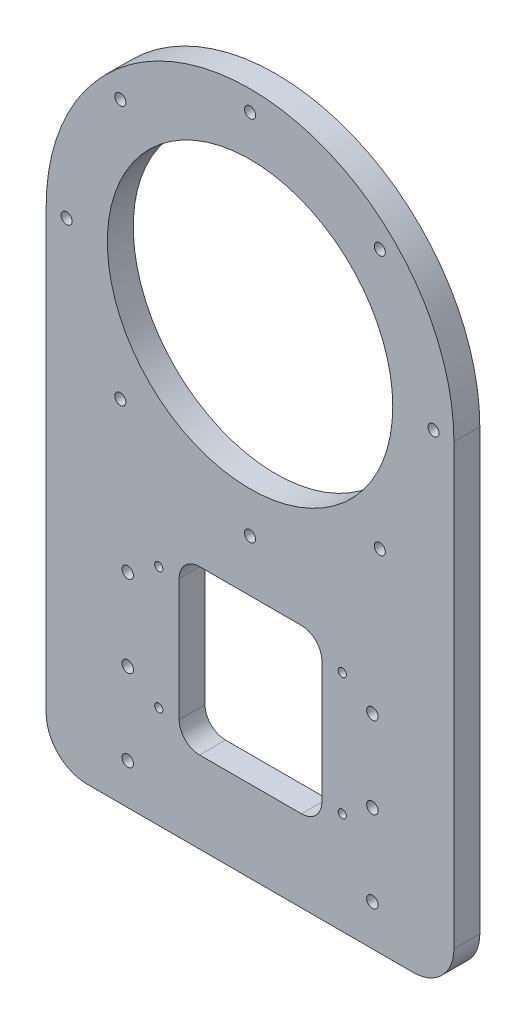
from build123d import *

# Parameters (mm, degrees)
SKETCH1_R             = 50
SKETCH1_R_2           = 35
BOSS_EXTRUDE1_DEPTH   = 6.35
BOSS_EXTRUDE2_DEPTH   = 6.35
F_6_32_TAPPED_HOLE1_D = 2.7051
FILLET1_R             = 10
M4X0_7_TAPPED_HOLE1_D = 2.8
SKETCH11_W            = 35
SKETCH11_H            = 40
CUT_EXTRUDE1_DEPTH    = 10
FILLET2_R             = 5
M3X0_5_TAPPED_HOLE1_D = 2


with BuildPart() as part:
    # Sketch1 → Boss-Extrude1 (new body)
    with BuildSketch(Plane.XY):
        Circle(SKETCH1_R)
        Circle(SKETCH1_R_2, mode=Mode.SUBTRACT)
    extrude(amount=BOSS_EXTRUDE1_DEPTH)

    # Sketch3 → Boss-Extrude2 (add)
    with BuildSketch(Plane.XY.offset(6.35)):
        with BuildLine():
            ThreePointArc((50, 0), (0, -50), (-50, 0))
            Line((-50, 0), (-50, -117.7))
            Line((-50, -117.7), (50, -117.7))
            Line((50, -117.7), (50, 0))
        make_face()
    extrude(amount=-BOSS_EXTRUDE2_DEPTH)

    # #6-32 Tapped Hole1 (through all)
    with Locations(Plane.XY.offset(6.35)):
        with Locations((-45, 0), (-31.819805153, -31.819805153), (0, -45), (31.819805153, -31.819805153), (45, 0), (31.819805153, 31.819805153), (0, 45), (-31.819805153, 31.819805153)):
            Hole(F_6_32_TAPPED_HOLE1_D / 2)

    # Fillet1
    fillet1_edges = [part.edges().sort_by_distance(p)[0] for p in [
        (-50, -117.7, 3.175),
        (50, -117.7, 3.175),
    ]]
    fillet(fillet1_edges, radius=FILLET1_R)

    # M4x0.7 Tapped Hole1 (through all)
    with Locations(Plane.XY.offset(6.35)):
        with Locations((-30, -107.7), (30, -107.7), (30, -87.7), (-30, -87.7), (30, -67.7), (-30, -67.7)):
            Hole(M4X0_7_TAPPED_HOLE1_D / 2)

    # Sketch11 → Cut-Extrude1 (cut)
    with BuildSketch(Plane(origin=(0, 0, 0), x_dir=(-1, 0, 0), z_dir=(0, 0, -1))):
        with Locations((-0.110004591, -77.7)):
            Rectangle(SKETCH11_W, SKETCH11_H)
    extrude(amount=-CUT_EXTRUDE1_DEPTH, mode=Mode.SUBTRACT)

    # Fillet2
    fillet2_edges = [part.edges().sort_by_distance(p)[0] for p in [
        (-17.389995409, -57.7, 3.175),
        (-17.389995409, -97.7, 3.175),
        (17.610004591, -97.7, 3.175),
        (17.610004591, -57.7, 3.175),
    ]]
    fillet(fillet2_edges, radius=FILLET2_R)

    # M3x0.5 Tapped Hole1 (through all)
    with Locations(Plane(origin=(0, 0, 0), x_dir=(-1, 0, 0), z_dir=(0, 0, -1))):
        with Locations((-22.610004591, -62.7), (-22.610004591, -92.7), (22.389995409, -92.7), (22.389995409, -62.7)):
            Hole(M3X0_5_TAPPED_HOLE1_D / 2)


solid = part.part
